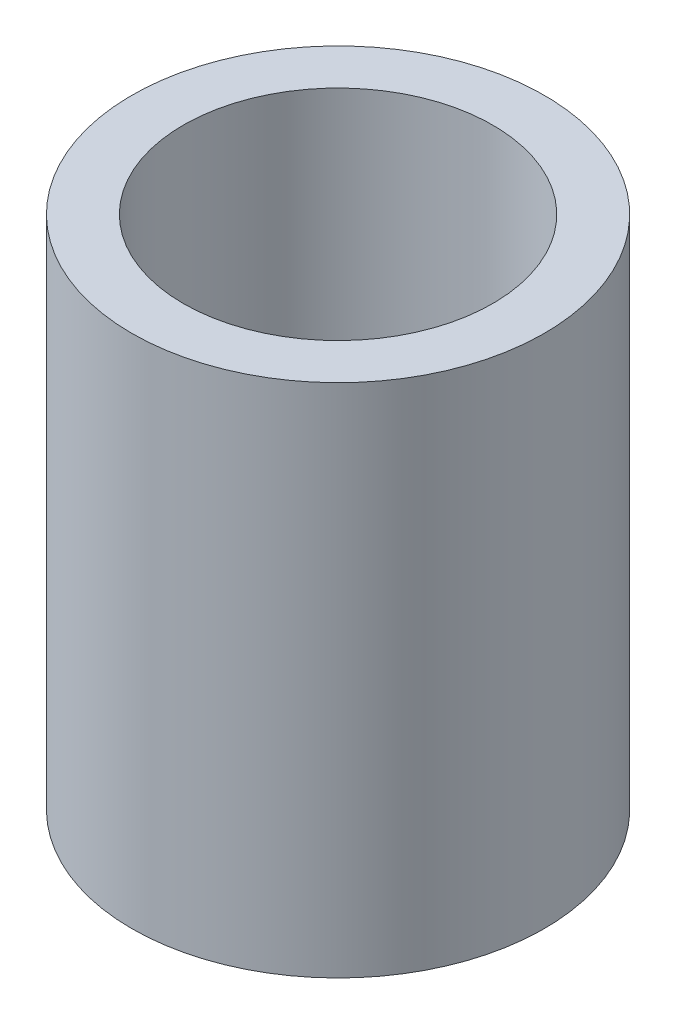
from build123d import *

# Parameters (mm, degrees)
SKETCH_1_R      = 2
SKETCH_1_R_2    = 1.5
EXTRUDE_1_DEPTH = 5


with BuildPart() as part:
    # 草图1 → 凸台-拉伸1 (new body)
    with BuildSketch(Plane(origin=(0, 0, 0), x_dir=(1, 0, 0), z_dir=(0, 1, 0))):
        Circle(SKETCH_1_R)
        Circle(SKETCH_1_R_2, mode=Mode.SUBTRACT)
    extrude(amount=EXTRUDE_1_DEPTH)


solid = part.part
